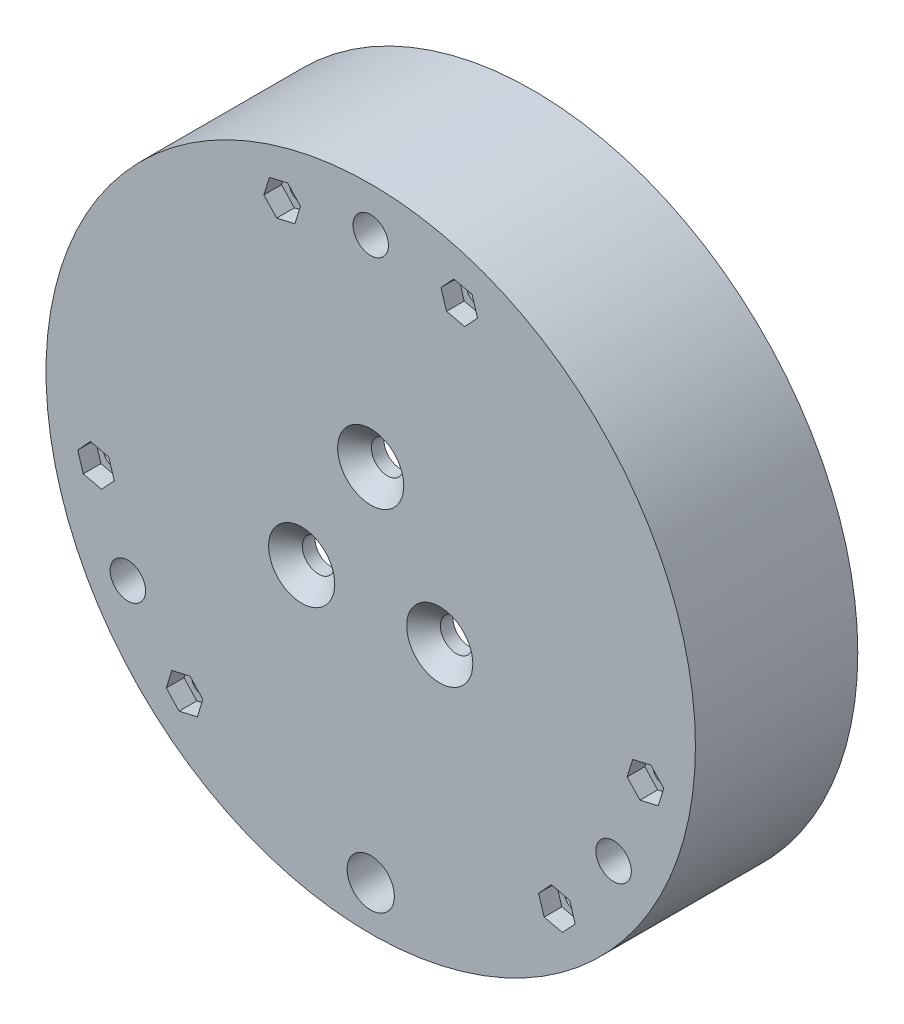
from build123d import *

# Parameters (mm, degrees)
CROQUIS1_R                                           = 55
CROQUIS1_R_2                                         = 52.5
SALIENTE_EXTRUIR1_DEPTH                              = 22.5
CROQUIS2_R                                           = 55
SALIENTE_EXTRUIR2_DEPTH                              = 5
REFRENTADO_PARA_TORNILLO_TAP_N_CON_CABEZ_D           = 5.5
REFRENTADO_PARA_TORNILLO_TAP_N_CON_CABEZ_CSINK_D     = 11.2
REFRENTADO_PARA_TORNILLO_TAP_N_CON_CABEZ_CSINK_ANGLE = 90
SALIENTE_EXTRUIR8_DEPTH                              = 10
CROQUIS12_R                                          = 3
CROQUIS12_R_2                                        = 4
CORTAR_EXTRUIR4_DEPTH                                = 10
CORTAR_EXTRUIR6_DEPTH                                = 3
CROQUIS16_R                                          = 1.75
CORTAR_EXTRUIR7_DEPTH                                = 5


with BuildPart() as part:
    # Croquis1 → Saliente-Extruir1 (new body)
    with BuildSketch(Plane.XY):
        Circle(CROQUIS1_R)
        Circle(CROQUIS1_R_2, mode=Mode.SUBTRACT)
    extrude(amount=SALIENTE_EXTRUIR1_DEPTH)

    # Croquis2 → Saliente-Extruir2 (add)
    with BuildSketch(Plane.XY.offset(22.5)):
        Circle(CROQUIS2_R)
    extrude(amount=SALIENTE_EXTRUIR2_DEPTH)

    # Refrentado para tornillo tapón con cabeza plana de clavija de M51 (through all)
    with Locations(Plane.XY.offset(27.5)):
        with Locations((0, 13.5), (-11.691342951, -6.75), (11.691342951, -6.75)):
            CounterSinkHole(REFRENTADO_PARA_TORNILLO_TAP_N_CON_CABEZ_D / 2, REFRENTADO_PARA_TORNILLO_TAP_N_CON_CABEZ_CSINK_D / 2, counter_sink_angle=REFRENTADO_PARA_TORNILLO_TAP_N_CON_CABEZ_CSINK_ANGLE)

    # Croquis10 → Saliente-Extruir8 (add)
    with BuildSketch(Plane(origin=(0, 0, 22.5), x_dir=(-1, 0, 0), z_dir=(0, 0, -1))):
        with BuildLine():
            Line((-3.5, 45), (-3.5, 51))
            ThreePointArc((-3.5, 51), (0, 54.5), (3.5, 51))
            Line((3.5, 51), (3.5, 45))
            ThreePointArc((3.5, 45), (0, 41.5), (-3.5, 45))
        make_face()
        with BuildLine():
            Line((40.72114317, -19.468911087), (45.917295593, -22.468911087))
            ThreePointArc((45.917295593, -22.468911087), (47.198384506, -27.25), (42.417295593, -28.531088913))
            Line((42.417295593, -28.531088913), (37.22114317, -25.531088913))
            ThreePointArc((37.22114317, -25.531088913), (35.940054257, -20.75), (40.72114317, -19.468911087))
        make_face()
        with BuildLine():
            Line((-37.22114317, -25.531088913), (-42.417295593, -28.531088913))
            ThreePointArc((-42.417295593, -28.531088913), (-47.198384506, -27.25), (-45.917295593, -22.468911087))
            Line((-45.917295593, -22.468911087), (-40.72114317, -19.468911087))
            ThreePointArc((-40.72114317, -19.468911087), (-35.940054257, -20.75), (-37.22114317, -25.531088913))
        make_face()
        with BuildLine():
            Line((-4.5, -50.030679936), (-4.5, -38.370856831))
            ThreePointArc((-4.5, -38.370856831), (0, -33.870856831), (4.5, -38.370856831))
            Line((4.5, -38.370856831), (4.5, -50.030679936))
            ThreePointArc((4.5, -50.030679936), (0, -54.530679936), (-4.5, -50.030679936))
        make_face()
    extrude(amount=SALIENTE_EXTRUIR8_DEPTH)

    # Croquis12 → Cortar-Extruir4 (cut)
    with BuildSketch(Plane.XY.offset(27.5)):
        with Locations((0, 47.5)):
            Circle(CROQUIS12_R)
        with Locations((41.13620668, -23.75)):
            Circle(CROQUIS12_R)
        with Locations((-41.13620668, -23.75)):
            Circle(CROQUIS12_R)
        with Locations((0, -47.5)):
            Circle(CROQUIS12_R_2)
    extrude(amount=-CORTAR_EXTRUIR4_DEPTH, mode=Mode.SUBTRACT)

    # Croquis15 → Cortar-Extruir6 (cut)
    with BuildSketch(Plane.XY.offset(27.5)):
        Polygon((-11.904987742, 45.779484215), (-14.067452684, 48.10479682), (-17.162464942, 47.394703548), (-18.095012258, 44.359297671), (-15.932547316, 42.033985067), (-12.837535058, 42.744078339), align=None)
        Polygon((18.095012258, 44.359297671), (15.932547316, 42.033985067), (12.837535058, 42.744078339), (11.904987742, 45.779484215), (14.067452684, 48.10479682), (17.162464942, 47.394703548), align=None)
        Polygon((44.368772548, -7.21900181), (43.436225232, -10.254407687), (45.598690174, -12.579720292), (48.693702432, -11.869627019), (49.626249748, -8.834221143), (47.463784806, -6.508908538), align=None)
        Polygon((34.626249748, -36.235169801), (32.463784806, -38.560482405), (29.368772548, -37.850389133), (28.436225232, -34.814983256), (30.598690174, -32.489670652), (33.693702432, -33.199763924), align=None)
        Polygon((-28.436225232, -34.814983256), (-30.598690174, -32.489670652), (-33.693702432, -33.199763924), (-34.626249748, -36.235169801), (-32.463784806, -38.560482405), (-29.368772548, -37.850389133), align=None)
        Polygon((-48.693702432, -11.869627019), (-49.626249748, -8.834221143), (-47.463784806, -6.508908538), (-44.368772548, -7.21900181), (-43.436225232, -10.254407687), (-45.598690174, -12.579720292), align=None)
    extrude(amount=-CORTAR_EXTRUIR6_DEPTH, mode=Mode.SUBTRACT)

    # Croquis16 → Cortar-Extruir7 (cut)
    with BuildSketch(Plane.XY.offset(27.5)):
        with Locations((-15.003552118, 45.088897544)):
            Circle(CROQUIS16_R)
        with Locations((15.003552118, 45.088897544)):
            Circle(CROQUIS16_R)
        with Locations((46.549906761, -9.55099149)):
            Circle(CROQUIS16_R)
        with Locations((31.546354642, -35.537906053)):
            Circle(CROQUIS16_R)
        with Locations((-31.546354642, -35.537906053)):
            Circle(CROQUIS16_R)
        with Locations((-46.549906761, -9.55099149)):
            Circle(CROQUIS16_R)
    extrude(amount=-CORTAR_EXTRUIR7_DEPTH, mode=Mode.SUBTRACT)


solid = part.part
